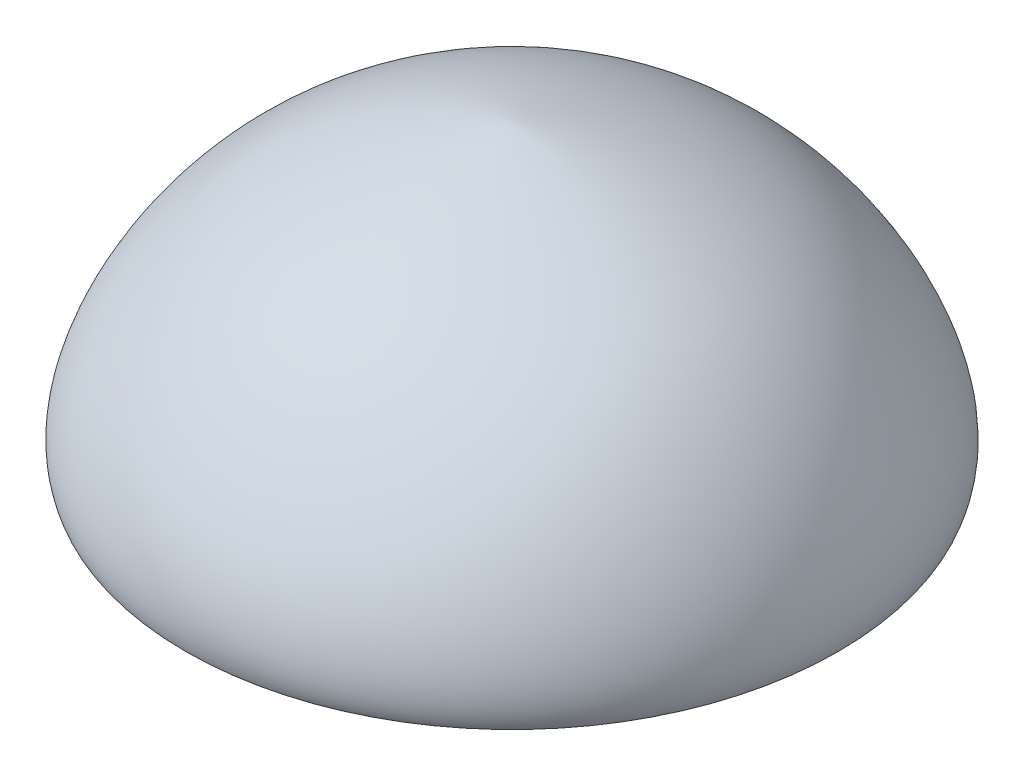
from build123d import *


with BuildPart() as part:
    # Sketch1 → Revolve1 (revolve)
    with BuildSketch(Plane.XY):
        with BuildLine():
            Line((0, 0.45), (0, 0))
            Line((0, 0), (0.5, 0))
            add(Edge.make_bspline(
                [(0.5, 0), (0.525443724, 0.062304504), (0.389704349, 0.378890471), (0.025490439, 0.45), (0, 0.45)],
                knots=[0, 0, 0, 0, 0.503823143, 1, 1, 1, 1], degree=3))
        make_face()
    revolve(axis=Axis((0, 0.45, 0), (0, -1, 0)))


solid = part.part
